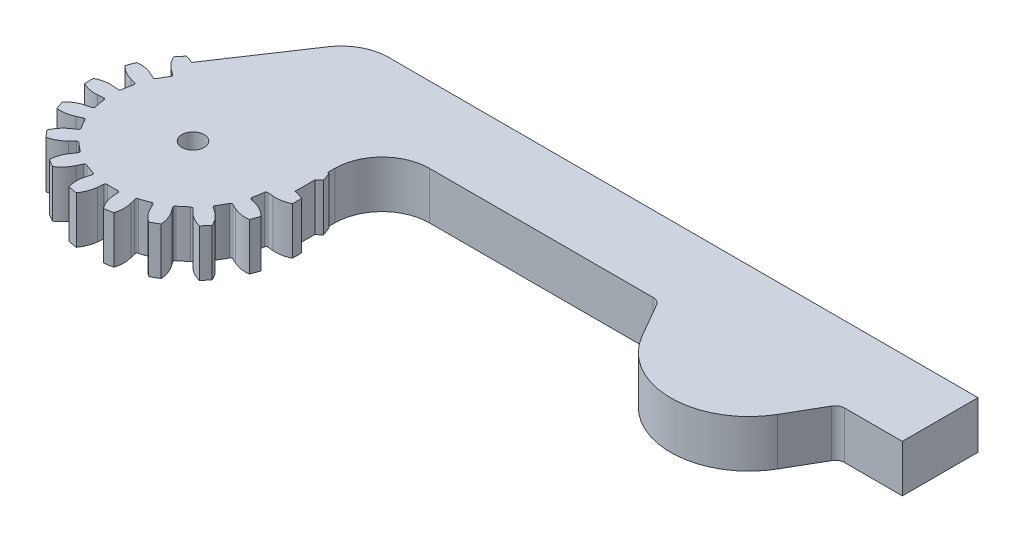
from build123d import *

# Parameters (mm, degrees)
BOSS_EXTRUDE1_DEPTH = 6.35
CIRPATTERN1_COUNT   = 18
BOSS_EXTRUDE2_START = -6.35
BOSS_EXTRUDE2_DEPTH = 6.35
SKETCH3_R           = 1.5
CUT_EXTRUDE1_DEPTH  = 6.35


with BuildPart() as part:
    # Sketch1 → Boss-Extrude1 (new body)
    with BuildSketch(Plane(origin=(0, 0, 0), x_dir=(1, 0, 0), z_dir=(0, 1, 0))):
        with BuildLine():
            Line((0, 10.82675), (0, 0))
            Line((0, 0), (-3.702966587, 10.173817082))
            ThreePointArc((-3.702966587, 10.173817082), (-3.373806035, 10.287660006), (-3.041154006, 10.390856455))
            ThreePointArc((-3.041154006, 10.390856455), (-2.891089042, 10.510159874), (-2.867155568, 10.700370251))
            Line((-2.867155568, 10.700370251), (-3.057799232, 11.411862094))
            ThreePointArc((-3.057799232, 11.411862094), (-3.196015561, 12.527739041), (-3.023661407, 13.638855219))
            ThreePointArc((-3.023661407, 13.638855219), (-2.725411799, 13.701570367), (-2.425865042, 13.75776431))
            ThreePointArc((-2.425865042, 13.75776431), (-2.125163705, 13.807410301), (-1.823450905, 13.850484713))
            ThreePointArc((-1.823450905, 13.850484713), (-1.281466864, 12.865325633), (-1.029695335, 11.769471531))
            Line((-1.029695335, 11.769471531), (-0.965497238, 11.035683923))
            ThreePointArc((-0.965497238, 11.035683923), (-0.877951347, 10.865130365), (-0.696132236, 10.804347064))
            ThreePointArc((-0.696132236, 10.804347064), (-0.348246314, 10.821147817), (0, 10.82675))
        make_face()
    boss_extrude1 = extrude(amount=BOSS_EXTRUDE1_DEPTH)

    # CirPattern1: Boss-Extrude1 ×18 about axis
    cirpattern1_axis = Axis((0, 0, 0), (0, 1, 0))
    for i in range(1, CIRPATTERN1_COUNT):
        add(boss_extrude1.rotate(cirpattern1_axis, i * 360 / CIRPATTERN1_COUNT))

    # Sketch2 → Boss-Extrude2 (add)
    with BuildSketch(Plane(origin=(0, 6.35, 0), x_dir=(1, 0, 0), z_dir=(0, 1, 0)).offset(BOSS_EXTRUDE2_START)):
        with BuildLine():
            ThreePointArc((12.7, 6.35), (14.559871939, 10.840128061), (19.05, 12.7))
            Line((19.05, 12.7), (49.084416739, 12.7))
            ThreePointArc((49.084416739, 12.7), (49.719416739, 12.529852263), (50.184269002, 12.065))
            Line((50.184269002, 12.065), (52.84909092, 7.449393046))
            ThreePointArc((52.84909092, 7.449393046), (61.943408936, 2.198786091), (71.037726951, 7.449393046))
            Line((71.037726951, 7.449393046), (73.702548869, 12.065))
            ThreePointArc((73.702548869, 12.065), (74.167401132, 12.529852263), (74.802401132, 12.7))
            Line((74.802401132, 12.7), (82.55, 12.7))
            Line((82.55, 12.7), (82.55, 22.86))
            Line((82.55, 22.86), (68.148522628, 22.86))
            Line((68.148522628, 22.86), (3.394217772, 22.86))
            ThreePointArc((3.394217772, 22.86), (0.400799065, 22.110173608), (-1.88567654, 20.037777778))
            Line((-1.88567654, 20.037777778), (-10.350886361, 7.368211835))
            Line((-10.350886361, 7.368211835), (0, 0))
            Line((0, 0), (12.7, 0))
            Line((12.7, 0), (12.7, 6.35))
        make_face()
    extrude(amount=BOSS_EXTRUDE2_DEPTH)

    # Sketch3 → Cut-Extrude1 (cut)
    with BuildSketch(Plane(origin=(0, 6.35, 0), x_dir=(1, 0, 0), z_dir=(0, 1, 0))):
        Circle(SKETCH3_R)
    extrude(amount=-CUT_EXTRUDE1_DEPTH, mode=Mode.SUBTRACT)


solid = part.part
